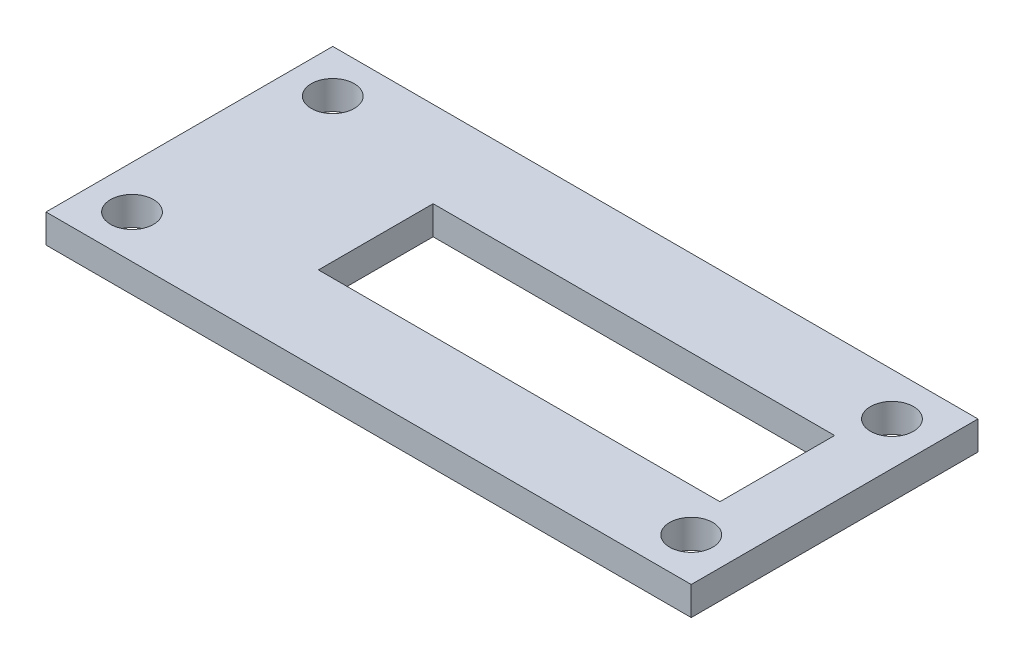
from build123d import *

# Parameters (mm, degrees)
CROQUIS2_W              = 45
CROQUIS2_H              = 20
SALIENTE_EXTRUIR1_DEPTH = 2
CROQUIS3_R              = 1.5
CORTAR_EXTRUIR1_DEPTH   = 3
CROQUIS4_W              = 28
CROQUIS4_H              = 8
CORTAR_EXTRUIR2_DEPTH   = 3


with BuildPart() as part:
    # Croquis2 → Saliente-Extruir1 (new body)
    with BuildSketch(Plane(origin=(0, 0, 0), x_dir=(1, 0, 0), z_dir=(0, 1, 0))):
        Rectangle(CROQUIS2_W, CROQUIS2_H)
    extrude(amount=SALIENTE_EXTRUIR1_DEPTH)

    # Croquis3 → Cortar-Extruir1 (cut, through all)
    with BuildSketch(Plane(origin=(0, 2, 0), x_dir=(1, 0, 0), z_dir=(0, 1, 0))):
        with Locations((-19.5, 7)):
            Circle(CROQUIS3_R)
        with Locations((19.5, 7)):
            Circle(CROQUIS3_R)
        with Locations((-19.5, -7)):
            Circle(CROQUIS3_R)
        with Locations((19.5, -7)):
            Circle(CROQUIS3_R)
    extrude(amount=-CORTAR_EXTRUIR1_DEPTH, mode=Mode.SUBTRACT)

    # Croquis4 → Cortar-Extruir2 (cut, through all)
    with BuildSketch(Plane(origin=(0, 2, 0), x_dir=(1, 0, 0), z_dir=(0, 1, 0))):
        with Locations((4.5, 0)):
            Rectangle(CROQUIS4_W, CROQUIS4_H)
    extrude(amount=-CORTAR_EXTRUIR2_DEPTH, mode=Mode.SUBTRACT)


solid = part.part
